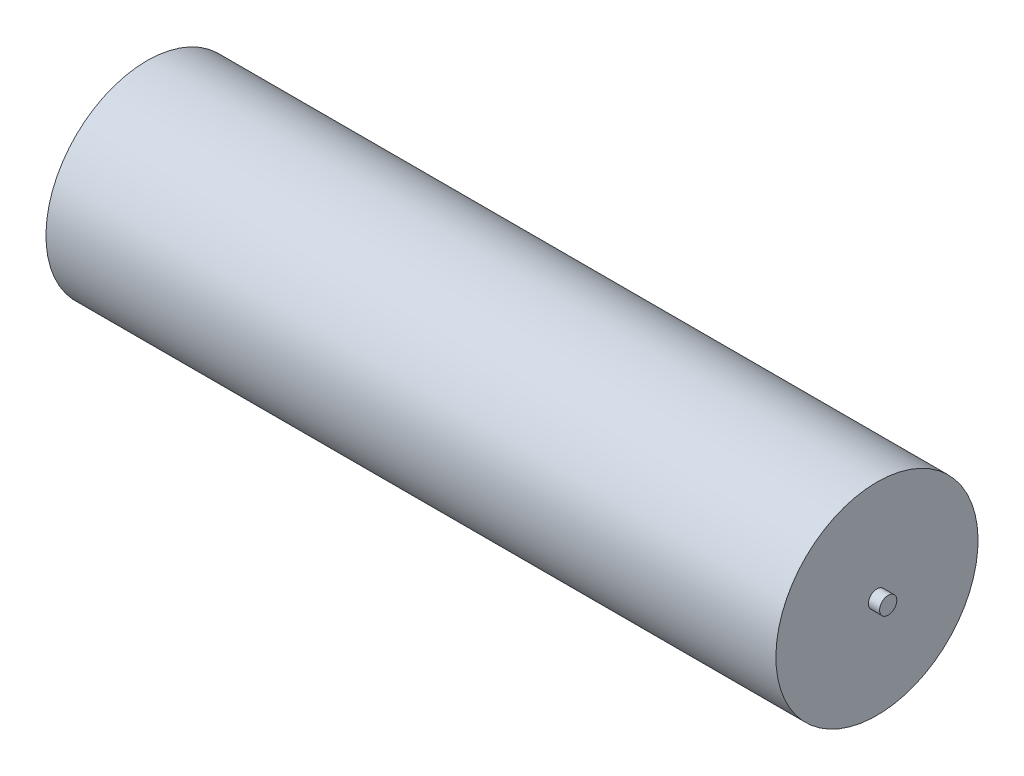
from build123d import *

# Parameters (mm, degrees)
SKETCH1_W           = 65
SKETCH1_H           = 9
SKETCH2_R           = 0.764525434
BOSS_EXTRUDE1_DEPTH = 1


with BuildPart() as part:
    # Sketch1 → Revolve1 (revolve)
    with BuildSketch(Plane.XY):
        with Locations((32.5, -4.5)):
            Rectangle(SKETCH1_W, SKETCH1_H)
    revolve(axis=Axis((65, -9, 0), (-1, 0, 0)))

    # Sketch2 → Boss-Extrude1 (add)
    with BuildSketch(Plane(origin=(65, 0, 0), x_dir=(0, 0, -1), z_dir=(1, 0, 0))):
        with Locations((0, -9)):
            Circle(SKETCH2_R)
    extrude(amount=BOSS_EXTRUDE1_DEPTH)


solid = part.part
